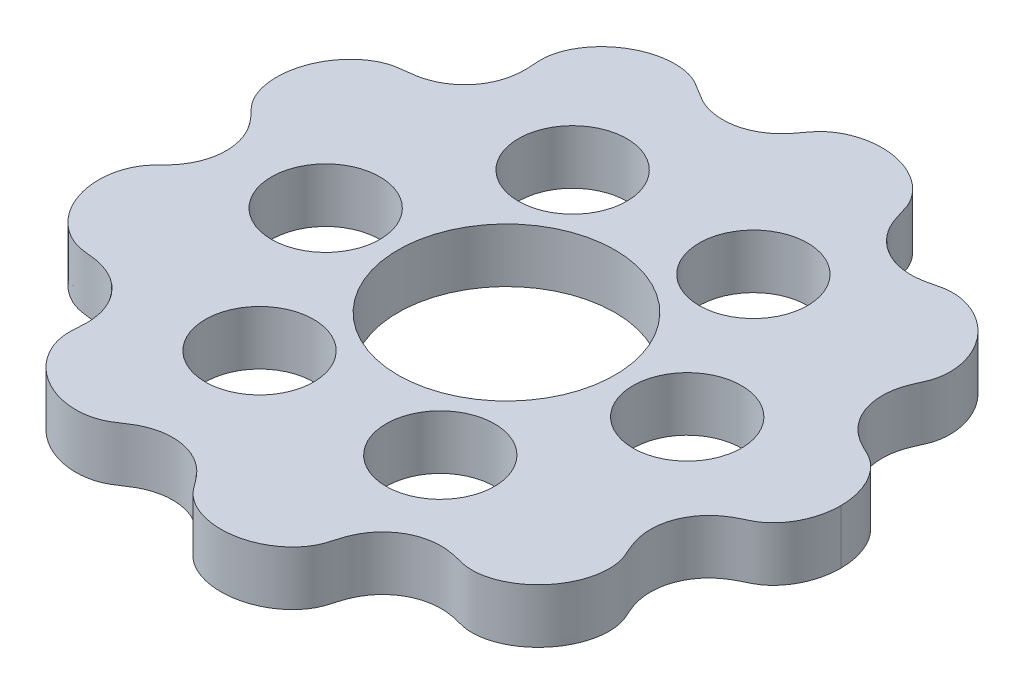
from build123d import *

# Parameters (mm, degrees)
SKETCH_1_R      = 3
SKETCH_1_R_2    = 6
EXTRUDE_1_DEPTH = 3


with BuildPart() as part:
    # 草图1 → 凸台-拉伸1 (new body)
    with BuildSketch(Plane(origin=(0, 0, 0), x_dir=(1, 0, 0), z_dir=(0, 1, 0))):
        with BuildLine():
            add(Edge.make_bspline(
                [(-15.500019091, 0.011031777), (-15.499124558, -0.247427331), (-15.529544967, -0.489070263), (-15.630461731, -0.932272098), (-15.696561016, -1.116920237), (-15.82740979, -1.422251827), (-15.89405836, -1.546828372), (-16.061540336, -1.832079697), (-16.150211367, -1.950058665), (-16.294010966, -2.134434564), (-16.350046346, -2.199008841), (-16.445150534, -2.306177143), (-16.482710618, -2.346453476), (-16.549031872, -2.416752869), (-16.576334743, -2.445057407), (-16.625487435, -2.49580845), (-16.64679004, -2.51763286), (-16.685205728, -2.557041863), (-16.702728299, -2.575028787), (-16.750139077, -2.623935541), (-16.776758954, -2.651749703), (-16.852261975, -2.732173192), (-16.89292421, -2.777827994), (-16.968891043, -2.867932632), (-17.003642234, -2.911837247), (-17.115804234, -3.062820758), (-17.186658185, -3.17461585), (-17.315968333, -3.416463049), (-17.37387882, -3.545879173), (-17.523673986, -3.955550816), (-17.590952188, -4.256701443), (-17.666850391, -5.090917237), (-17.605595672, -5.644190507), (-17.273451323, -6.686848163), (-17.002496884, -7.177060941), (-16.314345845, -7.988397329), (-15.896238635, -8.308071116), (-15.417314545, -8.529949792), (-15.361689562, -8.553633148), (-15.19503948, -8.618505745), (-15.084758287, -8.653424547), (-14.933236269, -8.69081145), (-14.893704253, -8.699622837), (-14.771891487, -8.72388494), (-14.690198299, -8.736776722), (-14.539802243, -8.754396664), (-14.49593256, -8.759075935), (-14.385171949, -8.770294812), (-14.321710528, -8.776206935), (-14.164835959, -8.793660864), (-14.093092032, -8.80182286), (-13.931958734, -8.826278198), (-13.863824105, -8.83744317), (-13.704045882, -8.86997927), (-13.6222978, -8.88820389), (-13.41315754, -8.946307321), (-13.292040342, -8.98384002), (-12.984893449, -9.108694454), (-12.802845227, -9.194309592), (-12.45585423, -9.417675919), (-12.30422739, -9.531377992), (-12.061478566, -9.754273863), (-11.96455707, -9.854683089), (-11.735865165, -10.12780543), (-11.624424717, -10.29323899), (-11.460551796, -10.586410657), (-11.401536604, -10.713120605), (-11.308347301, -10.944832806), (-11.273041749, -11.051532891), (-11.200658614, -11.304153372), (-11.174170765, -11.438090517), (-11.128474723, -11.725299228), (-11.119761057, -11.858399361), (-11.110715391, -12.068824874), (-11.11106826, -12.151167839), (-11.113485343, -12.286372806), (-11.115855731, -12.342044676), (-11.120542941, -12.435167846), (-11.123093465, -12.475805726), (-11.130062118, -12.580010556), (-11.134143328, -12.632383647), (-11.143879056, -12.763307584), (-11.147911737, -12.823216989), (-11.153415766, -12.933126059), (-11.154822784, -12.980805728), (-11.156042463, -13.124236629), (-11.152278777, -13.212941432), (-11.135615721, -13.393262652), (-11.122626144, -13.483658003), (-11.061159436, -13.797639484), (-10.988078467, -14.026694247), (-10.678433856, -14.713079114), (-10.350382798, -15.157760745), (-9.528956903, -15.889450643), (-9.035980823, -16.177524331), (-7.994289806, -16.53439468), (-7.444917695, -16.602363719), (-6.7603971, -16.541907181), (-6.586499211, -16.512089767), (-6.359050003, -16.453539301), (-6.297451573, -16.435497706), (-6.117079325, -16.376145507), (-6.003600974, -16.330020903), (-5.822909247, -16.241743403), (-5.754219233, -16.204452876), (-5.632955144, -16.131599465), (-5.584039677, -16.100629901), (-5.481739239, -16.032760543), (-5.434097091, -16.000313365), (-5.325458455, -15.926324355), (-5.274951748, -15.891724125), (-5.158902588, -15.815699929), (-5.107241227, -15.782312477), (-4.969757759, -15.699026099), (-4.883384092, -15.648167753), (-4.68356549, -15.547026723), (-4.583650201, -15.499519764), (-4.343476579, -15.40443804), (-4.196250613, -15.352616867), (-3.876690628, -15.275143633), (-3.719984652, -15.245781901), (-3.396879336, -15.216351686), (-3.24072245, -15.212016577), (-2.961033431, -15.22649181), (-2.837251004, -15.239657938), (-2.455782606, -15.304600891), (-2.222409579, -15.376010741), (-1.802210186, -15.551759847), (-1.631172759, -15.648838298), (-1.351982296, -15.830819903), (-1.240412263, -15.918182498), (-0.985038054, -16.135120305), (-0.883417432, -16.244062566), (-0.725449374, -16.419376829), (-0.671362954, -16.486180586), (-0.581959555, -16.599107235), (-0.548836383, -16.643136922), (-0.49104363, -16.720861566), (-0.467955515, -16.752631668), (-0.426451152, -16.809970033), (-0.408725594, -16.834650666), (-0.376505372, -16.879436042), (-0.361829652, -16.899814766), (-0.321991741, -16.954827335), (-0.299015331, -16.986111842), (-0.2564403, -17.042898204), (-0.236966821, -17.06825604), (-0.163765943, -17.161206413), (-0.114284252, -17.218950646), (-0.010308284, -17.330815143), (0.043384958, -17.383830439), (0.237449063, -17.559705541), (0.392835786, -17.674695307), (0.737473684, -17.880395297), (0.926104321, -17.970584639), (1.592181694, -18.217203398), (2.119439443, -18.300165757), (3.177059858, -18.258827561), (3.70762674, -18.135072864), (4.664940711, -17.707759716), (5.091489192, -17.403118118), (5.521164917, -16.938319492), (5.615533371, -16.820275048), (5.735406772, -16.64595707), (5.770191262, -16.591528829), (5.867616996, -16.427131619), (5.922805445, -16.317319572), (5.997318917, -16.139040866), (6.021465902, -16.074791541), (6.062667238, -15.951528503), (6.079421271, -15.897643424), (6.113025711, -15.782118446), (6.127455914, -15.730619712), (6.162044994, -15.608106624), (6.179043956, -15.547395975), (6.220684492, -15.410721598), (6.240157532, -15.348433797), (6.294748977, -15.191153318), (6.329864964, -15.093627227), (6.421067675, -14.887192539), (6.461533391, -14.801462344), (6.572934656, -14.595111915), (6.65167261, -14.461714185), (6.846952065, -14.195666308), (6.949884445, -14.070046032), (7.182837058, -13.835970468), (7.301382763, -13.731179967), (7.527350077, -13.561755005), (7.631053126, -13.492469333), (7.966322587, -13.297734332), (8.190524084, -13.203617345), (8.655628385, -13.0602052), (8.870935253, -13.025380716), (9.232378893, -12.990173159), (9.379598297, -12.989942214), (9.619302215, -12.998322948), (9.719392512, -13.007780592), (10.00863739, -13.04208954), (10.131431664, -13.069836329), (10.3210183, -13.111692809), (10.385855146, -13.128027638), (10.496170721, -13.155712666), (10.539293055, -13.166797764), (10.672267059, -13.200449632), (10.736205001, -13.215718129), (10.857350637, -13.241787747), (10.911262607, -13.2518699), (11.074150106, -13.277789432), (11.179218304, -13.287987176), (11.396775207, -13.29596017), (11.508069063, -13.293461474), (11.967073379, -13.255904393), (12.333539521, -13.163533203), (13.043291203, -12.855134575), (13.386082198, -12.639821921), (13.999670881, -12.112735397), (14.270659162, -11.801001741), (14.761618423, -11.035416896), (14.952449808, -10.564567241), (15.120363493, -9.722316844), (15.132133554, -9.351221469), (15.075892022, -8.938722386), (15.062538503, -8.863945021), (15.024649712, -8.692762553), (14.998202883, -8.598491073), (14.943752478, -8.439494359), (14.920090441, -8.377116187), (14.870797087, -8.25892248), (14.849477282, -8.209990967), (14.800407305, -8.100493655), (14.775546096, -8.04608137), (14.724796541, -7.931782277), (14.704191521, -7.884953152), (14.66108677, -7.782273326), (14.637897915, -7.725676257), (14.584441097, -7.584238647), (14.551164579, -7.492462241), (14.488916626, -7.280719506), (14.460741947, -7.174823523), (14.40948902, -6.913275287), (14.38397704, -6.747200148), (14.369372449, -6.40875647), (14.370734403, -6.256888483), (14.402243257, -5.932951716), (14.429876946, -5.767448967), (14.501280303, -5.489031583), (14.537250592, -5.374319202), (14.622853058, -5.148548905), (14.670564133, -5.041978882), (14.8248452, -4.73980189), (14.945755049, -4.558664871), (15.175102021, -4.267507543), (15.284186762, -4.153537012), (15.523762215, -3.92665693), (15.638727124, -3.838131269), (15.835704333, -3.695945765), (15.91318813, -3.646656534), (16.048948177, -3.563814293), (16.103749169, -3.532861388), (16.200036776, -3.479966606), (16.241810793, -3.458068214), (16.365923328, -3.394198146), (16.429213881, -3.363827), (16.533543953, -3.313427719), (16.574137308, -3.293952534), (16.645799116, -3.259059321), (16.676937404, -3.243653383), (16.734068998, -3.214754441), (16.759902368, -3.201354758), (16.850228629, -3.153251768), (16.906675345, -3.120686042), (17.016028555, -3.05262931), (17.068445803, -3.017342434), (17.222912834, -2.905117657), (17.322304297, -2.821651654), (17.623835655, -2.529976092), (17.812865139, -2.288136383), (18.220873018, -1.585783389), (18.392736167, -1.080755269), (18.487585506, -0.372681291), (18.5, -0.186322699), (18.5, 0)],
                knots=[72.028511686, 72.028511686, 72.028511686, 72.028511686, 72.074078367, 72.074078367, 72.119645047, 72.119645047, 72.165211728, 72.165211728, 72.248848234, 72.248848234, 72.33248474, 72.33248474, 72.416121246, 72.416121246, 72.499757752, 72.499757752, 72.583394258, 72.583394258, 72.667030764, 72.667030764, 72.834303777, 72.834303777, 73.189471491, 73.189471491, 73.544639205, 73.544639205, 74.389917585, 74.389917585, 75.235195964, 75.235195964, 76.925752723, 76.925752723, 79.739377541, 79.739377541, 82.553002358, 82.553002358, 85.366627176, 85.366627176, 85.735717822, 85.735717822, 86.473899114, 86.473899114, 86.732155716, 86.732155716, 87.248668919, 87.248668919, 87.435752622, 87.435752622, 87.622836326, 87.622836326, 87.739343397, 87.739343397, 87.806816675, 87.806816675, 87.862281518, 87.862281518, 87.917746361, 87.917746361, 87.973211204, 87.973211204, 88.010337889, 88.010337889, 88.035835328, 88.035835328, 88.073034576, 88.073034576, 88.101762564, 88.101762564, 88.130490553, 88.130490553, 88.176029193, 88.176029193, 88.248724857, 88.248724857, 88.321420522, 88.321420522, 88.394116186, 88.394116186, 88.46681185, 88.46681185, 88.612203178, 88.612203178, 88.885531286, 88.885531286, 89.158859394, 89.158859394, 89.737410773, 89.737410773, 90.315962152, 90.315962152, 91.721247903, 91.721247903, 94.574660048, 94.574660048, 97.428072194, 97.428072194, 100.281484339, 100.281484339, 101.299278557, 101.299278557, 101.689637002, 101.689637002, 102.470353892, 102.470353892, 102.973421887, 102.973421887, 103.292550505, 103.292550505, 103.517176503, 103.517176503, 103.6622859, 103.6622859, 103.750882102, 103.750882102, 103.839478305, 103.839478305, 103.896331213, 103.896331213, 103.949340978, 103.949340978, 103.988014945, 103.988014945, 104.018243484, 104.018243484, 104.04101129, 104.04101129, 104.086546903, 104.086546903, 104.132082516, 104.132082516, 104.177618129, 104.177618129, 104.262275127, 104.262275127, 104.346932125, 104.346932125, 104.431589123, 104.431589123, 104.516246121, 104.516246121, 104.600903119, 104.600903119, 104.685560117, 104.685560117, 104.854874113, 104.854874113, 105.024188108, 105.024188108, 105.509561058, 105.509561058, 105.994934008, 105.994934008, 107.167634515, 107.167634515, 108.340335021, 108.340335021, 111.071116083, 111.071116083, 113.801897144, 113.801897144, 116.532678205, 116.532678205, 117.4152437, 117.4152437, 117.811281291, 117.811281291, 118.603356475, 118.603356475, 119.037003147, 119.037003147, 119.337474118, 119.337474118, 119.536725344, 119.536725344, 119.679867492, 119.679867492, 119.767587406, 119.767587406, 119.85530732, 119.85530732, 119.902476243, 119.902476243, 119.955320949, 119.955320949, 119.994755089, 119.994755089, 120.025341291, 120.025341291, 120.04811125, 120.04811125, 120.093651169, 120.093651169, 120.145786843, 120.145786843, 120.197922518, 120.197922518, 120.250058192, 120.250058192, 120.385071486, 120.385071486, 120.52008478, 120.52008478, 120.655098075, 120.655098075, 120.988095274, 120.988095274, 121.321092474, 121.321092474, 122.009976703, 122.009976703, 122.698860932, 122.698860932, 124.789873957, 124.789873957, 126.880886981, 126.880886981, 128.971900006, 128.971900006, 131.572457117, 131.572457117, 133.656669444, 133.656669444, 134.131638945, 134.131638945, 134.76870687, 134.76870687, 135.175768627, 135.175768627, 135.42574342, 135.42574342, 135.608351109, 135.608351109, 135.702640539, 135.702640539, 135.778378178, 135.778378178, 135.858909598, 135.858909598, 135.913633764, 135.913633764, 135.96835793, 135.96835793, 136.003971559, 136.003971559, 136.036177677, 136.036177677, 136.057582462, 136.057582462, 136.078987247, 136.078987247, 136.121796817, 136.121796817, 136.164606386, 136.164606386, 136.225296669, 136.225296669, 136.285986952, 136.285986952, 136.346677235, 136.346677235, 136.407367518, 136.407367518, 136.559501691, 136.559501691, 136.711635864, 136.711635864, 136.863770037, 136.863770037, 137.01590421, 137.01590421, 137.421918727, 137.421918727, 137.827933244, 137.827933244, 138.639962277, 138.639962277, 140.372255597, 140.372255597, 143.100609726, 143.100609726, 144.058318639, 144.058318639, 144.058318639, 144.058318639], degree=3))
            add(Edge.make_bspline(
                [(18.5, 0), (18.5, 0.212241382), (18.483879528, 0.424519001), (18.388092022, 1.050816309), (18.260144293, 1.454392847), (17.898738441, 2.175903089), (17.665007662, 2.493130573), (17.342800625, 2.801008688), (17.278579441, 2.857017403), (17.131232186, 2.974187084), (17.047949554, 3.032880304), (16.93216204, 3.104786691), (16.904552017, 3.121284813), (16.818241833, 3.170866226), (16.757355828, 3.203429907), (16.636974877, 3.263482888), (16.589801218, 3.286360083), (16.466472574, 3.345796523), (16.391208503, 3.380855196), (16.222274347, 3.468257432), (16.169757354, 3.496048023), (16.055072395, 3.560646262), (15.988931675, 3.599182732), (15.821481083, 3.706220421), (15.709356475, 3.78147627), (15.450665914, 3.993073745), (15.306058263, 4.122458723), (15.0584962, 4.41091604), (14.96448628, 4.533428086), (14.780671346, 4.822322014), (14.696370689, 4.979980159), (14.574862016, 5.268292652), (14.531441756, 5.391461122), (14.463265757, 5.628254987), (14.437182434, 5.744471989), (14.389546756, 6.024237422), (14.376272073, 6.18380854), (14.369676412, 6.464784632), (14.375606531, 6.58876169), (14.395755156, 6.810175202), (14.410106153, 6.907419059), (14.46272945, 7.199814982), (14.504849389, 7.340778558), (14.56927994, 7.542565025), (14.595560771, 7.61423333), (14.64061187, 7.732101833), (14.660966179, 7.781874135), (14.712468565, 7.904874008), (14.73909853, 7.964247816), (14.783617479, 8.063570189), (14.801318519, 8.102593046), (14.832633843, 8.172355457), (14.845965797, 8.202392906), (14.870043211, 8.257631794), (14.880881783, 8.283052775), (14.91258749, 8.359247022), (14.930828431, 8.406055862), (14.985087281, 8.555376494), (15.014472259, 8.654145435), (15.062802011, 8.859846464), (15.081304327, 8.965952319), (15.127622436, 9.368973057), (15.118125542, 9.687475169), (14.976436194, 10.5004578), (14.782757216, 10.998296348), (14.214904081, 11.891967439), (13.840995309, 12.28840378), (12.990139046, 12.900761031), (12.512349444, 13.11593419), (11.898385809, 13.252240961), (11.752168254, 13.274054996), (11.538922003, 13.29061813), (11.469143791, 13.293475202), (11.262748871, 13.294375909), (11.130964053, 13.285058778), (10.942972865, 13.257352547), (10.889325446, 13.247913687), (10.789839688, 13.227501937), (10.746349091, 13.217811882), (10.663491969, 13.19801294), (10.627284173, 13.189049567), (10.540976321, 13.167237738), (10.491488986, 13.154467396), (10.385606349, 13.128023072), (10.338367826, 13.116349357), (10.220879742, 13.089282158), (10.149034438, 13.073263149), (9.99493989, 13.045041532), (9.924078863, 13.033166735), (9.732770319, 13.008440502), (9.596171777, 12.993824406), (9.252454914, 12.990736557), (9.053097175, 12.998001731), (8.558292705, 13.084227266), (8.252963084, 13.170040696), (7.820132868, 13.380285824), (7.685305743, 13.45786112), (7.442927906, 13.620944597), (7.332326943, 13.707345372), (7.084538321, 13.926380071), (6.963467612, 14.057416853), (6.769228776, 14.295539151), (6.693561302, 14.404827254), (6.569700327, 14.601078994), (6.52312435, 14.685334356), (6.444920479, 14.836761244), (6.413389839, 14.904407622), (6.347223643, 15.054605186), (6.318626378, 15.128499946), (6.271720808, 15.255953011), (6.254390203, 15.307213303), (6.22409333, 15.399944098), (6.212225332, 15.438309124), (6.191093732, 15.508086716), (6.181986894, 15.539159474), (6.158376668, 15.620727338), (6.146011538, 15.664884604), (6.114071099, 15.778278748), (6.098444551, 15.833033817), (6.069098996, 15.930672679), (6.055668732, 15.972835969), (6.016748718, 16.088032009), (5.990921462, 16.155613505), (5.904593831, 16.357620362), (5.835817154, 16.487707108), (5.67072808, 16.746273869), (5.574858263, 16.873473114), (5.155331998, 17.348624574), (4.74172346, 17.658798698), (3.805495082, 18.103584203), (3.283274033, 18.239229591), (2.234704478, 18.308156379), (1.708172034, 18.241053571), (0.893872231, 17.969054453), (0.581168047, 17.807197907), (0.242971083, 17.558139924), (0.170109593, 17.498589991), (0.060988065, 17.399834157), (0.021953638, 17.362274683), (-0.07792297, 17.260110328), (-0.135934474, 17.194750689), (-0.228304, 17.079771654), (-0.260292276, 17.038220735), (-0.31531229, 16.963901825), (-0.334633664, 16.937422811), (-0.378758422, 16.876359751), (-0.403402251, 16.841954184), (-0.466067739, 16.755146237), (-0.503362968, 16.703415625), (-0.594215578, 16.583512648), (-0.641360396, 16.522105936), (-0.750615524, 16.391979661), (-0.799310837, 16.335888446), (-0.920997405, 16.206464588), (-0.999819922, 16.126763441), (-1.19598074, 15.953597743), (-1.319671872, 15.852761556), (-1.594471679, 15.672190165), (-1.728359963, 15.593846539), (-2.021378157, 15.456449996), (-2.172324942, 15.397361998), (-2.448852294, 15.314703526), (-2.572800341, 15.285033028), (-2.831182263, 15.24035884), (-2.956910512, 15.226793548), (-3.32288583, 15.207589981), (-3.556144135, 15.22499239), (-3.94262333, 15.285916334), (-4.101445512, 15.327945903), (-4.368353367, 15.412677291), (-4.4723181, 15.454023009), (-4.651634409, 15.531629465), (-4.724662235, 15.567397288), (-4.846576771, 15.630179103), (-4.899319849, 15.659350982), (-5.014492639, 15.72535577), (-5.067648518, 15.758132212), (-5.160005493, 15.816341972), (-5.196640575, 15.840297423), (-5.262792143, 15.884057775), (-5.290251344, 15.902555249), (-5.367588259, 15.954882238), (-5.407311835, 15.982126598), (-5.477402175, 16.029703583), (-5.507233524, 16.049740927), (-5.561753547, 16.085746707), (-5.586910973, 16.102029926), (-5.662616226, 16.149941787), (-5.709221435, 16.177764031), (-5.853212874, 16.258674715), (-5.948424459, 16.304741316), (-6.15019582, 16.387783292), (-6.2556338, 16.424020305), (-6.689668379, 16.544852393), (-7.053410317, 16.585177798), (-7.802655233, 16.548766517), (-8.187438399, 16.472474034), (-9.080847308, 16.155521175), (-9.574125041, 15.859039123), (-10.390385256, 15.11123257), (-10.712806969, 14.658794465), (-10.968584704, 14.061735403), (-11.015516463, 13.928317513), (-11.073445476, 13.720230121), (-11.091234819, 13.644743967), (-11.134723777, 13.420312257), (-11.150548907, 13.275967277), (-11.155617338, 13.077499469), (-11.155652001, 13.028961661), (-11.153233618, 12.928962298), (-11.150981529, 12.87766073), (-11.144893614, 12.779354876), (-11.14201483, 12.73843366), (-11.134564385, 12.637884666), (-11.129980913, 12.580251179), (-11.12146309, 12.450389225), (-11.118022241, 12.394677174), (-11.112334246, 12.247040593), (-11.109593514, 12.158472284), (-11.116287825, 11.901946323), (-11.122024108, 11.739736976), (-11.190529477, 11.354458389), (-11.226273662, 11.194533724), (-11.33204404, 10.879805809), (-11.387986579, 10.738671231), (-11.553699858, 10.407947756), (-11.666442234, 10.224833142), (-11.88003806, 9.952188392), (-11.961505186, 9.85974348), (-12.124826956, 9.693687851), (-12.208318482, 9.617831), (-12.420355397, 9.443554547), (-12.549137121, 9.354671893), (-12.784505298, 9.211700478), (-12.892817201, 9.155840705), (-13.091307448, 9.063908873), (-13.181403203, 9.028031295), (-13.46252702, 8.926192931), (-13.606918541, 8.891852116), (-13.815029755, 8.84639685), (-13.890555434, 8.833241999), (-14.015440631, 8.813244078), (-14.068867353, 8.805954758), (-14.201584951, 8.788982417), (-14.266385748, 8.78235195), (-14.37483059, 8.77122641), (-14.417514801, 8.767041372), (-14.493650233, 8.75927421), (-14.526348234, 8.755799393), (-14.586312466, 8.749022074), (-14.613779001, 8.745694435), (-14.695907228, 8.735017743), (-14.745825918, 8.727363348), (-14.900251819, 8.70000713), (-14.998398386, 8.676671163), (-15.196710798, 8.617345665), (-15.295676838, 8.581479139), (-15.631417974, 8.437647224), (-15.868317812, 8.298333552), (-16.475994126, 7.829219192), (-16.819165198, 7.434860261), (-17.338091729, 6.53369894), (-17.514624264, 6.02690625), (-17.66732409, 5.000638754), (-17.642754184, 4.480881158), (-17.471947661, 3.80042947), (-17.398908773, 3.597555307), (-17.282761103, 3.354524998), (-17.253601367, 3.298356784), (-17.161963669, 3.135243834), (-17.095867376, 3.034300847), (-16.980996623, 2.882586036), (-16.937496731, 2.829313751), (-16.869534857, 2.75209669), (-16.850528505, 2.731001119), (-16.794681854, 2.670425082), (-16.755642553, 2.629475279), (-16.665000084, 2.53625027), (-16.6220673, 2.492710157), (-16.529456292, 2.396139079), (-16.492455754, 2.357259143), (-16.408665735, 2.265450721), (-16.365876409, 2.217666064), (-16.273227262, 2.10711937), (-16.227314612, 2.050467543), (-16.123749731, 1.912128291), (-16.060794589, 1.82356144), (-15.926998355, 1.606630204), (-15.850777308, 1.471795059), (-15.71786311, 1.169667977), (-15.660525542, 1.017917495), (-15.57421338, 0.699612723), (-15.542669907, 0.544805294), (-15.508722628, 0.264705153), (-15.500466358, 0.140261331), (-15.500019091, 0.011031777)],
                knots=[0, 0, 0, 0, 1.090932366, 1.090932366, 3.272797099, 3.272797099, 5.454661831, 5.454661831, 5.982975045, 5.982975045, 6.641918815, 6.641918815, 6.841906186, 6.841906186, 7.241880929, 7.241880929, 7.449679718, 7.449679718, 7.657478507, 7.657478507, 7.729132843, 7.729132843, 7.792125173, 7.792125173, 7.864805622, 7.864805622, 7.925552176, 7.925552176, 7.959669443, 7.959669443, 7.99378671, 7.99378671, 8.016370377, 8.016370377, 8.038954043, 8.038954043, 8.071840719, 8.071840719, 8.104727395, 8.104727395, 8.13761407, 8.13761407, 8.218998974, 8.218998974, 8.285929367, 8.285929367, 8.35285976, 8.35285976, 8.486720546, 8.486720546, 8.620581332, 8.620581332, 8.754442118, 8.754442118, 8.888302903, 8.888302903, 9.180615187, 9.180615187, 9.853153662, 9.853153662, 10.525692136, 10.525692136, 12.32497112, 12.32497112, 15.056525933, 15.056525933, 17.788080746, 17.788080746, 20.519635559, 20.519635559, 21.384037621, 21.384037621, 21.812996668, 21.812996668, 22.670914762, 22.670914762, 23.006766585, 23.006766585, 23.240907544, 23.240907544, 23.395554038, 23.395554038, 23.550200532, 23.550200532, 23.645925676, 23.645925676, 23.741650821, 23.741650821, 23.799337152, 23.799337152, 23.872912732, 23.872912732, 23.934488131, 23.934488131, 23.996063529, 23.996063529, 24.022838857, 24.022838857, 24.049614185, 24.049614185, 24.08816295, 24.08816295, 24.126711714, 24.126711714, 24.165260479, 24.165260479, 24.203809243, 24.203809243, 24.264023534, 24.264023534, 24.324237825, 24.324237825, 24.384452115, 24.384452115, 24.444666406, 24.444666406, 24.565094988, 24.565094988, 24.803478955, 24.803478955, 25.041862921, 25.041862921, 25.500219941, 25.500219941, 26.441035141, 26.441035141, 27.381850342, 27.381850342, 30.089225854, 30.089225854, 32.796601367, 32.796601367, 35.50397688, 35.50397688, 37.474460929, 37.474460929, 38.059420469, 38.059420469, 38.405995574, 38.405995574, 38.972118512, 38.972118512, 39.254763743, 39.254763743, 39.389710413, 39.389710413, 39.524657083, 39.524657083, 39.659603752, 39.659603752, 39.757662743, 39.757662743, 39.814731031, 39.814731031, 39.87179932, 39.87179932, 39.925118776, 39.925118776, 39.962420875, 39.962420875, 39.99371728, 39.99371728, 40.016823956, 40.016823956, 40.039930632, 40.039930632, 40.086143984, 40.086143984, 40.132357336, 40.132357336, 40.178570688, 40.178570688, 40.22478404, 40.22478404, 40.270997392, 40.270997392, 40.34285925, 40.34285925, 40.414721107, 40.414721107, 40.486582965, 40.486582965, 40.635615434, 40.635615434, 40.784647904, 40.784647904, 40.933680373, 40.933680373, 41.259137263, 41.259137263, 41.950599302, 41.950599302, 42.642061341, 42.642061341, 44.674853779, 44.674853779, 46.707646217, 46.707646217, 49.582966182, 49.582966182, 52.458286148, 52.458286148, 53.280644633, 53.280644633, 53.753503899, 53.753503899, 54.69922243, 54.69922243, 54.996402874, 54.996402874, 55.270206494, 55.270206494, 55.434984244, 55.434984244, 55.599761993, 55.599761993, 55.696666749, 55.696666749, 55.793571504, 55.793571504, 55.89047626, 55.89047626, 55.941195535, 55.941195535, 55.975651693, 55.975651693, 56.016335236, 56.016335236, 56.037813097, 56.037813097, 56.059290957, 56.059290957, 56.091584893, 56.091584893, 56.123878828, 56.123878828, 56.156172764, 56.156172764, 56.237965978, 56.237965978, 56.304944359, 56.304944359, 56.37192274, 56.37192274, 56.505879502, 56.505879502, 56.639836264, 56.639836264, 56.773793026, 56.773793026, 56.907749789, 56.907749789, 57.201674212, 57.201674212, 57.860340894, 57.860340894, 58.519007577, 58.519007577, 60.0899673, 60.0899673, 62.780353688, 62.780353688, 65.470740076, 65.470740076, 68.161126464, 68.161126464, 69.401906558, 69.401906558, 69.789761423, 69.789761423, 70.565471153, 70.565471153, 70.999232051, 70.999232051, 71.154269094, 71.154269094, 71.419837003, 71.419837003, 71.600923291, 71.600923291, 71.69554792, 71.69554792, 71.771018597, 71.771018597, 71.826906595, 71.826906595, 71.882794593, 71.882794593, 71.935748807, 71.935748807, 71.975181758, 71.975181758, 72.005728346, 72.005728346, 72.028511686, 72.028511686, 72.028511686, 72.028511686], degree=3))
        make_face()
        with Locations((10, 0)):
            Circle(SKETCH_1_R, mode=Mode.SUBTRACT)
        with Locations((5, 8.660254038)):
            Circle(SKETCH_1_R, mode=Mode.SUBTRACT)
        with Locations((-5, 8.660254038)):
            Circle(SKETCH_1_R, mode=Mode.SUBTRACT)
        with Locations((-10, 0)):
            Circle(SKETCH_1_R, mode=Mode.SUBTRACT)
        with Locations((-5, -8.660254038)):
            Circle(SKETCH_1_R, mode=Mode.SUBTRACT)
        with Locations((5, -8.660254038)):
            Circle(SKETCH_1_R, mode=Mode.SUBTRACT)
        Circle(SKETCH_1_R_2, mode=Mode.SUBTRACT)
    extrude(amount=EXTRUDE_1_DEPTH)


solid = part.part
